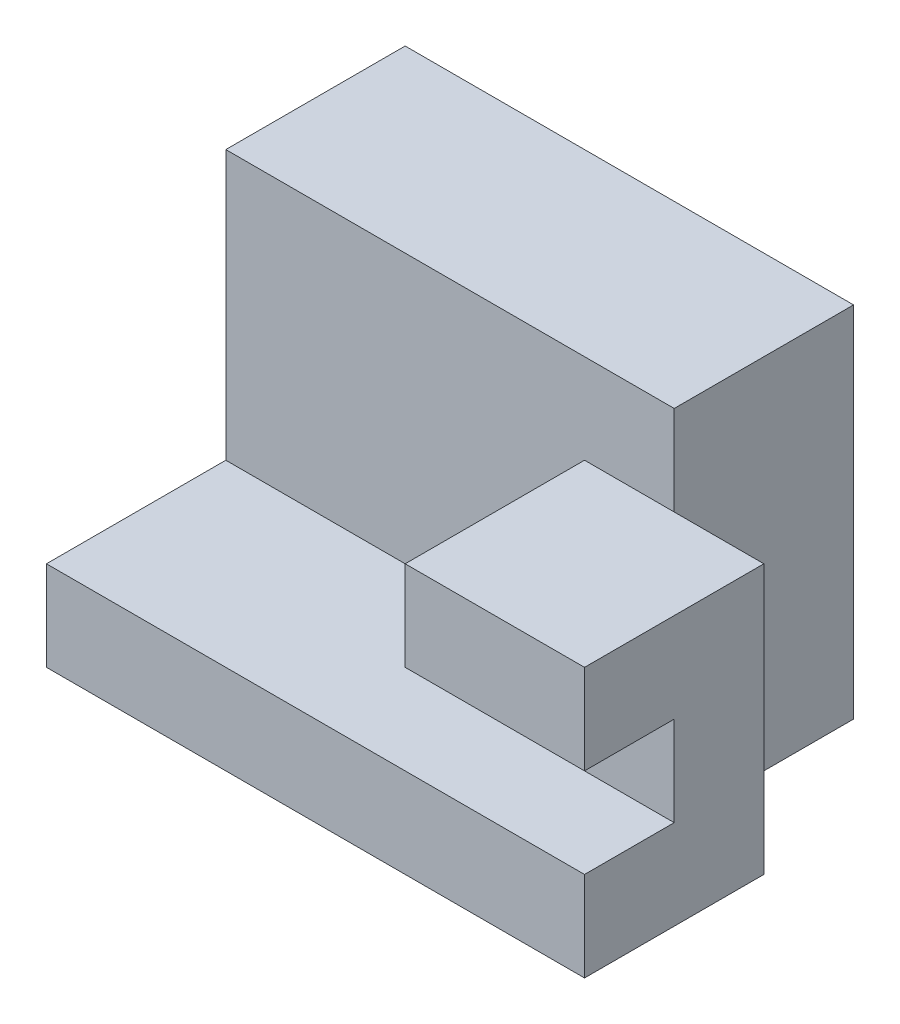
from build123d import *

# Parameters (mm, degrees)
SKETCH_1_W      = 5
SKETCH_1_H      = 2
EXTRUDE_1_DEPTH = 4
EXTRUDE_2_DEPTH = 1
EXTRUDE_3_DEPTH = 2


with BuildPart() as part:
    # 草圖1 → 填料-伸長1 (new body)
    with BuildSketch(Plane(origin=(0, 0, 0), x_dir=(1, 0, 0), z_dir=(0, 1, 0))):
        with Locations((2.5, 1)):
            Rectangle(SKETCH_1_W, SKETCH_1_H)
    extrude(amount=EXTRUDE_1_DEPTH)

    # 草圖1<3> → 填料-伸長2 (add)
    with BuildSketch(Plane(origin=(0, 0, 0), x_dir=(1, 0, 0), z_dir=(0, 1, 0))):
        Polygon((5, 0), (0, 0), (0, -2), (6, -2), (6, 0), align=None)
    extrude(amount=EXTRUDE_2_DEPTH)

    # 草圖2 → 填料-伸長3 (add)
    with BuildSketch(Plane(origin=(6, 0, 0), x_dir=(0, 0, -1), z_dir=(1, 0, 0))):
        Polygon((-1, 1), (0, 1), (0, 3), (-2, 3), (-2, 2), (-1, 2), align=None)
    extrude(amount=-EXTRUDE_3_DEPTH)


solid = part.part
